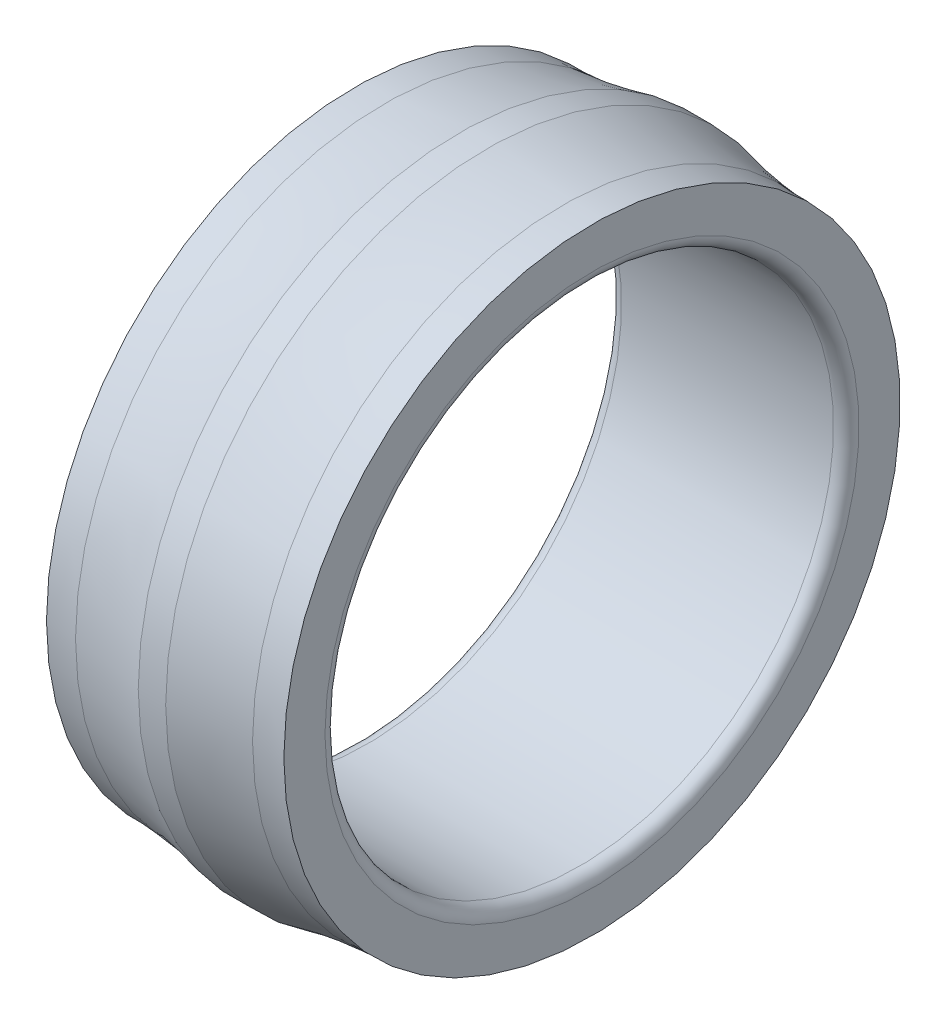
from build123d import *


with BuildPart() as part:
    # Sketch1 → Revolve1 (revolve)
    with BuildSketch(Plane.XY):
        with BuildLine():
            Line((1.5, 30), (26.5, 30))
            ThreePointArc((26.5, 30), (27.560660172, 30.439339828), (28, 31.5))
            Line((28, 31.5), (28, 36.35))
            ThreePointArc((28, 36.35), (26.217439951, 36.360351084), (24.439151002, 36.484108463))
            ThreePointArc((24.439151002, 36.484108463), (19.996363113, 36.996457171), (15.617923853, 37.907574657))
            Line((15.617923853, 37.907574657), (12.382076147, 37.907574657))
            ThreePointArc((12.382076147, 37.907574657), (8.003636887, 36.996457171), (3.560848998, 36.484108463))
            ThreePointArc((3.560848998, 36.484108463), (1.782560049, 36.360351084), (0, 36.35))
            Line((0, 36.35), (0, 31.5))
            ThreePointArc((0, 31.5), (0.439339828, 30.439339828), (1.5, 30))
        make_face()
    revolve(axis=Axis((28, 0, 0), (-1, 0, 0)))


solid = part.part
